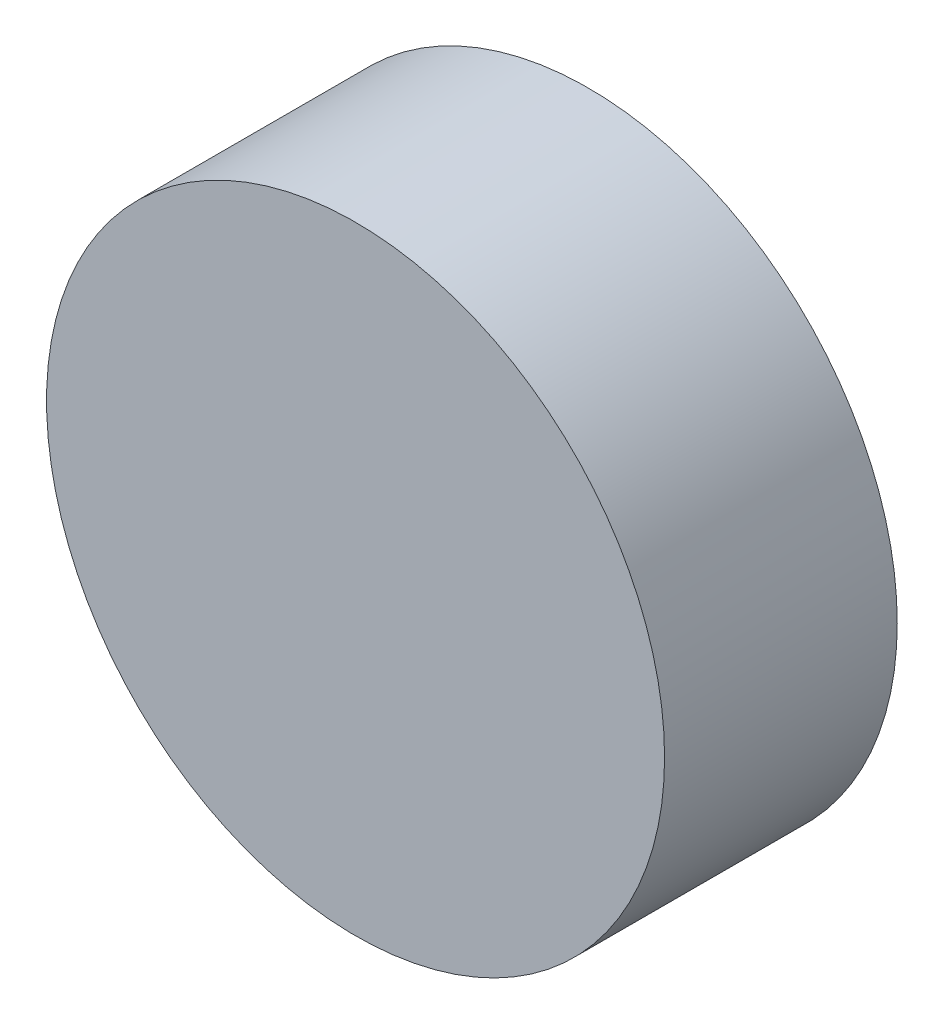
from build123d import *

# Parameters (mm, degrees)
SKETCH_1_R      = 42.5
EXTRUDE_1_DEPTH = 32
SKETCH_1_3_R    = 5.4
EXTRUDE_2_DEPTH = 10


with BuildPart() as part:
    # 草图1 → 凸台-拉伸1 (new body)
    with BuildSketch(Plane.XY):
        Circle(SKETCH_1_R)
    extrude(amount=EXTRUDE_1_DEPTH)

    # 草图1<3> → 凸台-拉伸2 (add)
    with BuildSketch(Plane.XY):
        Circle(SKETCH_1_3_R)
    extrude(amount=-EXTRUDE_2_DEPTH)


solid = part.part
